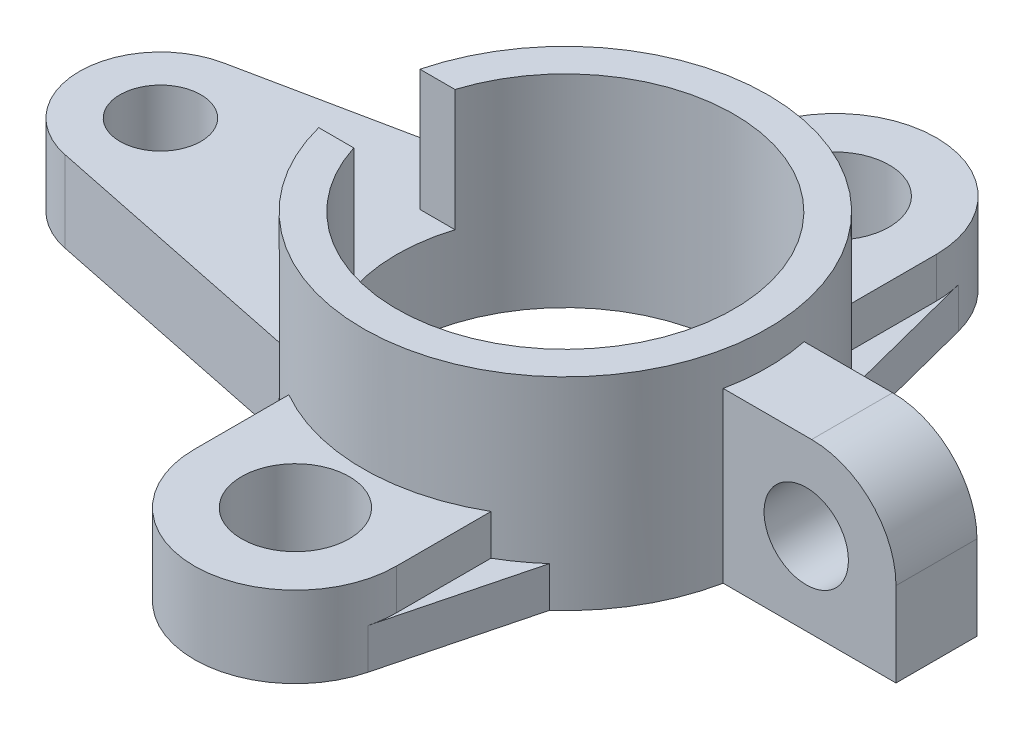
from build123d import *

# Parameters (mm, degrees)
Y_KSEKLIK_EKSTR_ZYON2_DEPTH = 30
IZIM1_7_R                   = 6
IZIM1_7_R_2                 = 7.987749768
Y_KSEKLIK_EKSTR_ZYON3_DEPTH = 12
Y_KSEKLIK_EKSTR_ZYON6_DEPTH = 6
Y_KSEKLIK_EKSTR_ZYON7_DEPTH = 25
RADYUS1_R                   = 12.5
IZIM2_R                     = 6.25
KES_EKSTR_ZYON1_DEPTH       = 100.007092258


with BuildPart() as part:
    # Çizim1 → Yükseklik-Ekstrüzyon2 (new body)
    with BuildSketch(Plane(origin=(0, 0, 0), x_dir=(1, 0, 0), z_dir=(0, 1, 0))):
        with BuildLine():
            ThreePointArc((-20, 22.360679775), (-21.213203436, 21.213203436), (-22.360679775, 20))
            ThreePointArc((-22.360679775, 20), (-26.452968197, 14.150635095), (-29.047375097, 7.5))
            Line((-29.047375097, 7.5), (-23.848480035, 7.5))
            ThreePointArc((-23.848480035, 7.5), (3.793942482, 24.710443145), (25, 0))
            ThreePointArc((25, 0), (3.793942482, -24.710443145), (-23.848480035, -7.5))
            Line((-23.848480035, -7.5), (-29.047375097, -7.5))
            ThreePointArc((-29.047375097, -7.5), (-26.452968197, -14.150635095), (-22.360679775, -20))
            ThreePointArc((-22.360679775, -20), (-21.213203436, -21.213203436), (-20, -22.360679775))
            ThreePointArc((-20, -22.360679775), (-17.58340753, -24.306866923), (-14.978720201, -25.993036397))
            ThreePointArc((-14.978720201, -25.993036397), (0, -30), (14.978720201, -25.993036397))
            ThreePointArc((14.978720201, -25.993036397), (17.58340753, -24.306866923), (20, -22.360679775))
            ThreePointArc((20, -22.360679775), (26.016470356, -14.937980794), (29.393876913, -6))
            ThreePointArc((29.393876913, -6), (30, 0), (29.393876913, 6))
            ThreePointArc((29.393876913, 6), (26.016470356, 14.937980794), (20, 22.360679775))
            ThreePointArc((20, 22.360679775), (17.58340753, 24.306866923), (14.978720201, 25.993036397))
            ThreePointArc((14.978720201, 25.993036397), (0, 30), (-14.978720201, 25.993036397))
            ThreePointArc((-14.978720201, 25.993036397), (-17.58340753, 24.306866923), (-20, 22.360679775))
        make_face()
    extrude(amount=Y_KSEKLIK_EKSTR_ZYON2_DEPTH)

    # Çizim1<7> → Yükseklik-Ekstrüzyon3 (add)
    # profile 1 of 3: a face of its own
    with BuildSketch(Plane(origin=(0, 0, 0), x_dir=(1, 0, 0), z_dir=(0, 1, 0))):
        with BuildLine():
            Line((-22.360679775, 20), (-62.419565489, 11.753540013))
            ThreePointArc((-62.419565489, 11.753540013), (-72, 0), (-62.419565489, -11.753540013))
            Line((-62.419565489, -11.753540013), (-22.360679775, -20))
            ThreePointArc((-22.360679775, -20), (-26.452968197, -14.150635095), (-29.047375097, -7.5))
            Line((-29.047375097, -7.5), (-23.848480035, -7.5))
            ThreePointArc((-23.848480035, -7.5), (-25, 0), (-23.848480035, 7.5))
            Line((-23.848480035, 7.5), (-29.047375097, 7.5))
            ThreePointArc((-29.047375097, 7.5), (-26.452968197, 14.150635095), (-22.360679775, 20))
        make_face()
        with Locations((-60, 0)):
            Circle(IZIM1_7_R, mode=Mode.SUBTRACT)
    # profile 2 of 3: a face of its own
    with BuildSketch(Plane(origin=(0, 0, 0), x_dir=(1, 0, 0), z_dir=(0, 1, 0))):
        with BuildLine():
            ThreePointArc((14.978720201, 40), (0, 54.978720201), (-14.978720201, 40))
            Line((-14.978720201, 40), (-14.978720201, 25.993036397))
            ThreePointArc((-14.978720201, 25.993036397), (0, 30), (14.978720201, 25.993036397))
            Line((14.978720201, 25.993036397), (14.978720201, 40))
        make_face()
        with Locations((0, 40)):
            Circle(IZIM1_7_R_2, mode=Mode.SUBTRACT)
    # profile 3 of 3: a face of its own
    with BuildSketch(Plane(origin=(0, 0, 0), x_dir=(1, 0, 0), z_dir=(0, 1, 0))):
        with BuildLine():
            ThreePointArc((-14.978720201, -40), (0, -54.978720201), (14.978720201, -40))
            Line((14.978720201, -40), (14.978720201, -25.993036397))
            ThreePointArc((14.978720201, -25.993036397), (0, -30), (-14.978720201, -25.993036397))
            Line((-14.978720201, -25.993036397), (-14.978720201, -40))
        make_face()
        with Locations((0, -40)):
            Circle(IZIM1_7_R_2, mode=Mode.SUBTRACT)
    extrude(amount=Y_KSEKLIK_EKSTR_ZYON3_DEPTH)

    # Çizim1<12> → Yükseklik-Ekstrüzyon6 (add)
    with BuildSketch(Plane(origin=(0, 0, 0), x_dir=(1, 0, 0), z_dir=(0, 1, 0))):
        with BuildLine():
            Line((-14.507084908, 43.729148203), (-20, 22.360679775))
            ThreePointArc((-20, 22.360679775), (-17.58340753, 24.306866923), (-14.978720201, 25.993036397))
            Line((-14.978720201, 25.993036397), (-14.978720201, 40))
            ThreePointArc((-14.978720201, 40), (-14.860343614, 41.879427184), (-14.507084908, 43.729148203))
        make_face()
        with BuildLine():
            ThreePointArc((-14.978720201, -25.993036397), (-17.58340753, -24.306866923), (-20, -22.360679775))
            Line((-20, -22.360679775), (-14.507084908, -43.729148203))
            ThreePointArc((-14.507084908, -43.729148203), (-14.860343614, -41.879427184), (-14.978720201, -40))
            Line((-14.978720201, -40), (-14.978720201, -25.993036397))
        make_face()
        with BuildLine():
            Line((20, 22.360679775), (14.507084908, 43.729148203))
            ThreePointArc((14.507084908, 43.729148203), (14.860343614, 41.879427184), (14.978720201, 40))
            Line((14.978720201, 40), (14.978720201, 25.993036397))
            ThreePointArc((14.978720201, 25.993036397), (17.58340753, 24.306866923), (20, 22.360679775))
        make_face()
        with BuildLine():
            ThreePointArc((14.978720201, -40), (14.860343614, -41.879427184), (14.507084908, -43.729148203))
            Line((14.507084908, -43.729148203), (20, -22.360679775))
            ThreePointArc((20, -22.360679775), (17.58340753, -24.306866923), (14.978720201, -25.993036397))
            Line((14.978720201, -25.993036397), (14.978720201, -40))
        make_face()
    extrude(amount=Y_KSEKLIK_EKSTR_ZYON6_DEPTH)

    # Çizim1<13> → Yükseklik-Ekstrüzyon7 (add)
    with BuildSketch(Plane(origin=(0, 0, 0), x_dir=(1, 0, 0), z_dir=(0, 1, 0))):
        with BuildLine():
            Line((55, 6), (29.393876913, 6))
            ThreePointArc((29.393876913, 6), (30, 0), (29.393876913, -6))
            Line((29.393876913, -6), (55, -6))
            Line((55, -6), (55, 6))
        make_face()
    extrude(amount=Y_KSEKLIK_EKSTR_ZYON7_DEPTH)

    # Radyus1
    radyus1_edges = [part.edges().sort_by_distance(p)[0] for p in [
        (55, 25, 0),
    ]]
    fillet(radyus1_edges, radius=RADYUS1_R)

    # Çizim2 → Kes-Ekstrüzyon1 (cut, through all)
    with BuildSketch(Plane.XY.offset(6)):
        with Locations((41.698353051, 12.200101709)):
            Circle(IZIM2_R)
    extrude(amount=-KES_EKSTR_ZYON1_DEPTH, mode=Mode.SUBTRACT)


solid = part.part
